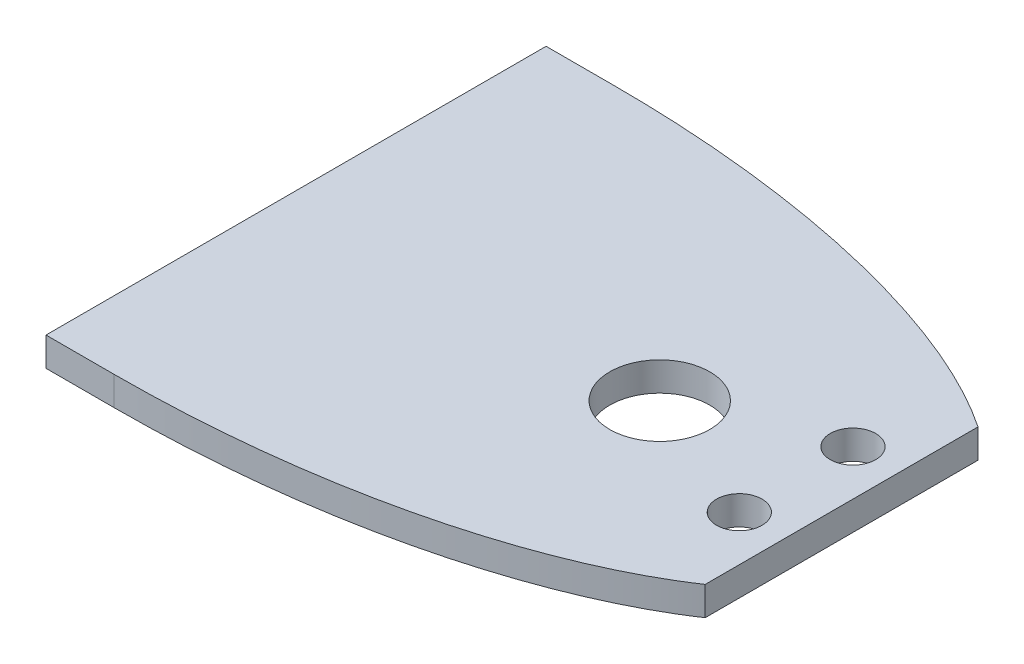
from build123d import *

# Parameters (mm, degrees)
BOSS_EXTRUDE1_DEPTH = 6.35
SKETCH2_R           = 5
CUT_EXTRUDE1_DEPTH  = 6.35
SKETCH3_R           = 11
CUT_EXTRUDE2_DEPTH  = 7.3500001
SKETCH4_W           = 15
SKETCH4_H           = 110
BOSS_EXTRUDE3_DEPTH = 6.35


with BuildPart() as part:
    # Sketch1 → Boss-Extrude1 (new body)
    with BuildSketch(Plane(origin=(0, 0, 0), x_dir=(1, 0, 0), z_dir=(0, 1, 0))):
        with BuildLine():
            Line((0, 110), (0, 0))
            add(Edge.make_bspline(
                [(0, 0), (67.941176471, 0), (105, 25)],
                knots=[1.570796327, 1.570796327, 1.570796327, 2.564661308, 2.564661308, 2.564661308], degree=2, weights=[1, 0.879049073, 1]))
            Line((105, 25), (105, 85))
            add(Edge.make_bspline(
                [(105, 85), (67.941176471, 110), (0, 110)],
                knots=[3.718523999, 3.718523999, 3.718523999, 4.71238898, 4.71238898, 4.71238898], degree=2, weights=[1, 0.879049073, 1]))
        make_face()
    extrude(amount=BOSS_EXTRUDE1_DEPTH)

    # Sketch2 → Cut-Extrude1 (cut)
    with BuildSketch(Plane(origin=(0, 0, 0), x_dir=(1, 0, 0), z_dir=(0, 1, 0))):
        with Locations((95, 67.5)):
            Circle(SKETCH2_R)
        with Locations((95, 42.5)):
            Circle(SKETCH2_R)
    extrude(amount=CUT_EXTRUDE1_DEPTH, mode=Mode.SUBTRACT)

    # Sketch3 → Cut-Extrude2 (cut, through all)
    with BuildSketch(Plane(origin=(0, 0, 0), x_dir=(1, 0, 0), z_dir=(0, 1, 0))):
        with Locations((65, 55)):
            Circle(SKETCH3_R)
    extrude(amount=CUT_EXTRUDE2_DEPTH, mode=Mode.SUBTRACT)

    # Sketch4 → Boss-Extrude3 (add)
    with BuildSketch(Plane(origin=(0, 0, 0), x_dir=(1, 0, 0), z_dir=(0, 1, 0))):
        with Locations((-7.5, 55)):
            Rectangle(SKETCH4_W, SKETCH4_H)
    extrude(amount=BOSS_EXTRUDE3_DEPTH)


solid = part.part
